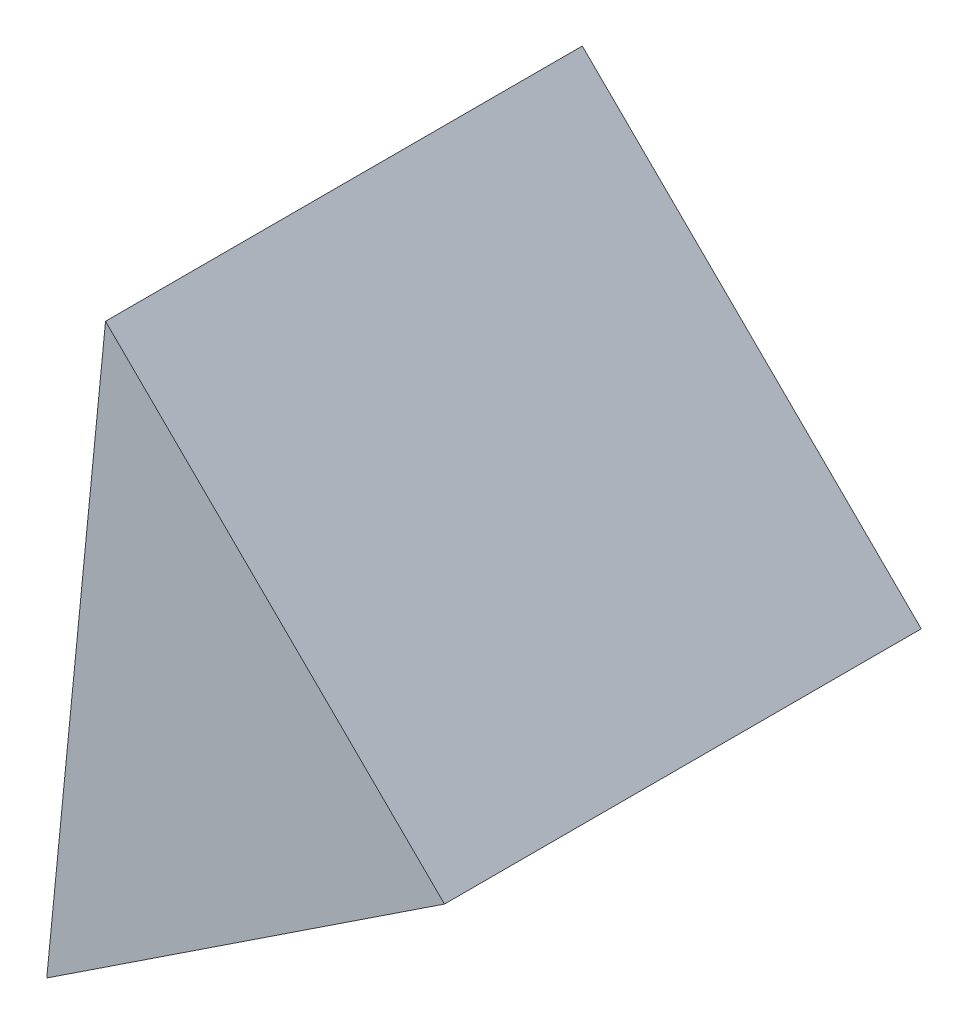
from build123d import *

# Parameters (mm, degrees)
EXTRUDE_1_DEPTH = 20


with BuildPart() as part:
    # 草图2 → 凸台-拉伸1 (new body)
    with BuildSketch(Plane.XY):
        Polygon((17.370970729, 11.875501625), (3.151514257, 25.939891325), (0.686170974, 0.847471105), align=None)
    extrude(amount=EXTRUDE_1_DEPTH)


solid = part.part
